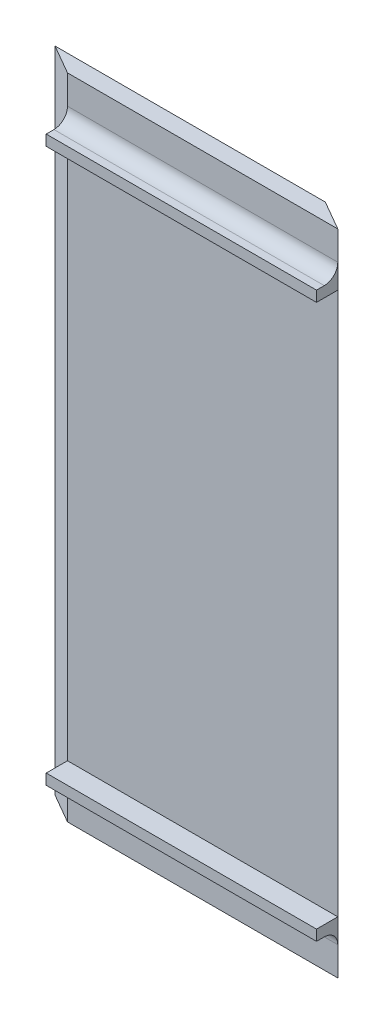
from build123d import *

# Parameters (mm, degrees)
SKETCH1_W           = 50.8
SKETCH1_H           = 121.92
BOSS_EXTRUDE1_DEPTH = 3.2
CUT_EXTRUDE1_DEPTH  = 122.92
BOSS_EXTRUDE2_DEPTH = 121.92
SKETCH5_W           = 50.8
SKETCH5_H           = 2
BOSS_EXTRUDE3_DEPTH = 4
FILLET1_R           = 2.54


with BuildPart() as part:
    # Sketch1 → Boss-Extrude1 (new body)
    with BuildSketch(Plane.XY):
        with Locations((28.39261314, -60.96)):
            Rectangle(SKETCH1_W, SKETCH1_H)
    extrude(amount=-BOSS_EXTRUDE1_DEPTH)

    # Sketch2 → Cut-Extrude1 (cut, through all)
    with BuildSketch(Plane.XZ.offset(121.92)):
        Polygon((53.79261314, 0), (53.79261314, -3.2), (48.250050556, -3.2), align=None)
    extrude(amount=-CUT_EXTRUDE1_DEPTH, mode=Mode.SUBTRACT)

    # Sketch4 → Boss-Extrude2 (add)
    with BuildSketch(Plane.XZ.offset(121.92)):
        Polygon((2.99261314, 0), (2.99261314, -3.2), (-2.549949444, -3.2), align=None)
    extrude(amount=-BOSS_EXTRUDE2_DEPTH)

    # Sketch5 → Boss-Extrude3 (add)
    with BuildSketch(Plane.XY):
        with Locations((28.39261314, -8.96)):
            Rectangle(SKETCH5_W, SKETCH5_H)
        with Locations((28.39261314, -112.96)):
            Rectangle(SKETCH5_W, SKETCH5_H)
    extrude(amount=BOSS_EXTRUDE3_DEPTH)

    # Fillet1
    fillet1_edges = [part.edges().sort_by_distance(p)[0] for p in [
        (28.39261314, -7.96, 0),
        (28.39261314, -113.96, 0),
    ]]
    fillet(fillet1_edges, radius=FILLET1_R)


solid = part.part
